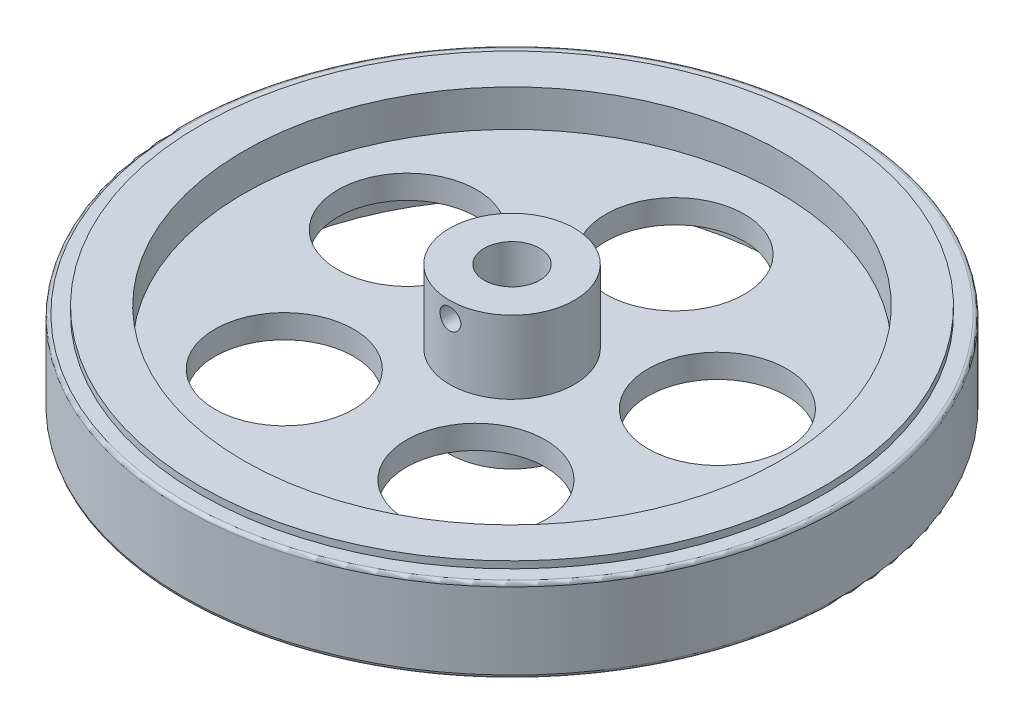
from build123d import *

# Parameters (mm, degrees)
SKETCH_1_R          = 47.5
SKETCH_1_R_2        = 9
SKETCH_1_R_3        = 4
EXTRUDE_1_DEPTH     = 7
SKETCH_2_R          = 47.5
SKETCH_2_R_2        = 45
CUT_EXTRUDE_1_DEPTH = 1
SKETCH_3_R          = 38.66
SKETCH_3_R_2        = 9
CUT_EXTRUDE_2_DEPTH = 5.3
SKETCH_4_R          = 10
CUT_EXTRUDE_3_DEPTH = 9.7
FILLET_1_R          = 0.5
SKETCH_5_R          = 9
SKETCH_5_R_2        = 4
EXTRUDE_2_DEPTH     = 5.2
SKETCH_6_R          = 1.5
CUT_EXTRUDE_4_DEPTH = 48.5000001


with BuildPart() as part:
    # 草圖1 → 填料-伸長1 (new body, symmetric)
    with BuildSketch(Plane(origin=(0, 0, 0), x_dir=(1, 0, 0), z_dir=(0, 1, 0))):
        Circle(SKETCH_1_R)
        Circle(SKETCH_1_R_2, mode=Mode.SUBTRACT)
        Circle(SKETCH_1_R_2)
        Circle(SKETCH_1_R_3, mode=Mode.SUBTRACT)
    extrude(amount=EXTRUDE_1_DEPTH, both=True)

    # 草圖2 → 除料-伸長1 (cut)
    with BuildSketch(Plane(origin=(0, 7, 0), x_dir=(1, 0, 0), z_dir=(0, 1, 0))):
        Circle(SKETCH_2_R)
        Circle(SKETCH_2_R_2, mode=Mode.SUBTRACT)
    cut_extrude_1 = extrude(amount=-CUT_EXTRUDE_1_DEPTH, mode=Mode.SUBTRACT)

    # 鏡射1: 除料-伸長1 across plane
    add(cut_extrude_1.mirror(Plane.ZX), mode=Mode.SUBTRACT)

    # 草圖3 → 除料-伸長2 (cut)
    with BuildSketch(Plane(origin=(0, 7, 0), x_dir=(1, 0, 0), z_dir=(0, 1, 0))):
        Circle(SKETCH_3_R)
        Circle(SKETCH_3_R_2, mode=Mode.SUBTRACT)
    cut_extrude_2 = extrude(amount=-CUT_EXTRUDE_2_DEPTH, mode=Mode.SUBTRACT)

    # 鏡射2: 除料-伸長2 across plane
    add(cut_extrude_2.mirror(Plane.ZX), mode=Mode.SUBTRACT)

    # 草圖4 → 除料-伸長3 (cut, through all)
    with BuildSketch(Plane(origin=(0, 1.7, 0), x_dir=(1, 0, 0), z_dir=(0, 1, 0))):
        with Locations((0, 23.5)):
            Circle(SKETCH_4_R)
        with Locations((22.349828133, 7.261899368)):
            Circle(SKETCH_4_R)
        with Locations((13.812953429, -19.011899368)):
            Circle(SKETCH_4_R)
        with Locations((-13.812953429, -19.011899368)):
            Circle(SKETCH_4_R)
        with Locations((-22.349828133, 7.261899368)):
            Circle(SKETCH_4_R)
    extrude(amount=-CUT_EXTRUDE_3_DEPTH, mode=Mode.SUBTRACT)

    # 圓角1
    fillet_1_edges = [part.edges().sort_by_distance(p)[0] for p in [
        (-47.5, 6, 0),
        (-47.5, -6, 0),
    ]]
    fillet(fillet_1_edges, radius=FILLET_1_R)

    # 草圖5 → 填料-伸長2 (add)
    with BuildSketch(Plane(origin=(0, 7, 0), x_dir=(1, 0, 0), z_dir=(0, 1, 0))):
        Circle(SKETCH_5_R)
        Circle(SKETCH_5_R_2, mode=Mode.SUBTRACT)
    extrude(amount=EXTRUDE_2_DEPTH)

    # 草圖6 → 除料-伸長4 (cut, through all)
    with BuildSketch(Plane.XY):
        with Locations((0, 9.9)):
            Circle(SKETCH_6_R)
    extrude(amount=CUT_EXTRUDE_4_DEPTH, mode=Mode.SUBTRACT)


solid = part.part
